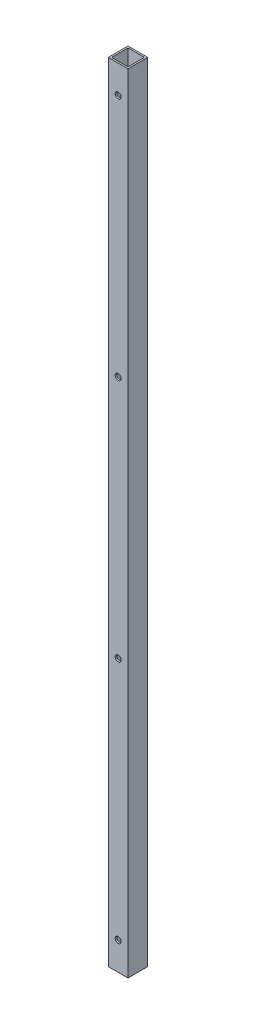
from build123d import *

# Parameters (mm, degrees)
SKETCH1_W                      = 19
SKETCH1_H                      = 19
SKETCH1_W_2                    = 15.875
SKETCH1_H_2                    = 15.875
TUBE_DEPTH                     = 758.9266
SKETCH2_R                      = 2.8956
SIDE_WALL_HOLES_DEPTH          = 20
LPATTERN1_COUNT                = 4
LPATTERN1_PITCH                = 234.974466667
CUT_EXTRUDE1_REACH             = 21
SKETCH3_R                      = 4.7625
CUT_EXTRUDE1_DIRECTION_2_DEPTH = 1


with BuildPart() as part:
    # Sketch1 → Tube (new body)
    with BuildSketch(Plane(origin=(0, 0, 0), x_dir=(1, 0, 0), z_dir=(0, 1, 0))):
        Rectangle(SKETCH1_W, SKETCH1_H)
        Rectangle(SKETCH1_W_2, SKETCH1_H_2, mode=Mode.SUBTRACT)
    extrude(amount=TUBE_DEPTH)

    # Sketch2 → Side Wall Holes (cut, through all)
    with BuildSketch(Plane.XY.offset(9.5)):
        with Locations((0, 731.925)):
            Circle(SKETCH2_R)
    side_wall_holes = extrude(amount=-SIDE_WALL_HOLES_DEPTH, mode=Mode.SUBTRACT)

    # LPattern1: Side Wall Holes ×4
    with Locations(*[(0, -i * LPATTERN1_PITCH, 0) for i in range(1, LPATTERN1_COUNT)]):
        add(side_wall_holes, mode=Mode.SUBTRACT)

    # Sketch3 → Cut-Extrude1 (cut, up to next)
    with BuildSketch(Plane.ZY.offset(9.5), mode=Mode.PRIVATE) as cut_extrude1_sk1:
        with Locations((0, 674.37)):
            Circle(SKETCH3_R)
    cut_extrude1_tool1 = extrude(cut_extrude1_sk1.sketch, amount=-CUT_EXTRUDE1_REACH, mode=Mode.PRIVATE) & part.part
    add(cut_extrude1_tool1.solids().sort_by_distance((-9.5, 674.37, 0))[0], mode=Mode.SUBTRACT)
    # Sketch3 → Cut-Extrude1 (cut, up to next)
    with BuildSketch(Plane.ZY.offset(9.5), mode=Mode.PRIVATE) as cut_extrude1_sk2:
        with Locations((0, 84.5566)):
            Circle(SKETCH3_R)
    cut_extrude1_tool2 = extrude(cut_extrude1_sk2.sketch, amount=-CUT_EXTRUDE1_REACH, mode=Mode.PRIVATE) & part.part
    add(cut_extrude1_tool2.solids().sort_by_distance((-9.5, 84.5566, 0))[0], mode=Mode.SUBTRACT)

    # Sketch3 → Cut-Extrude1 direction 2 (cut)
    with BuildSketch(Plane.ZY.offset(9.5)):
        with Locations((0, 674.37)):
            Circle(SKETCH3_R)
        with Locations((0, 84.5566)):
            Circle(SKETCH3_R)
    extrude(amount=CUT_EXTRUDE1_DIRECTION_2_DEPTH, mode=Mode.SUBTRACT)


solid = part.part
